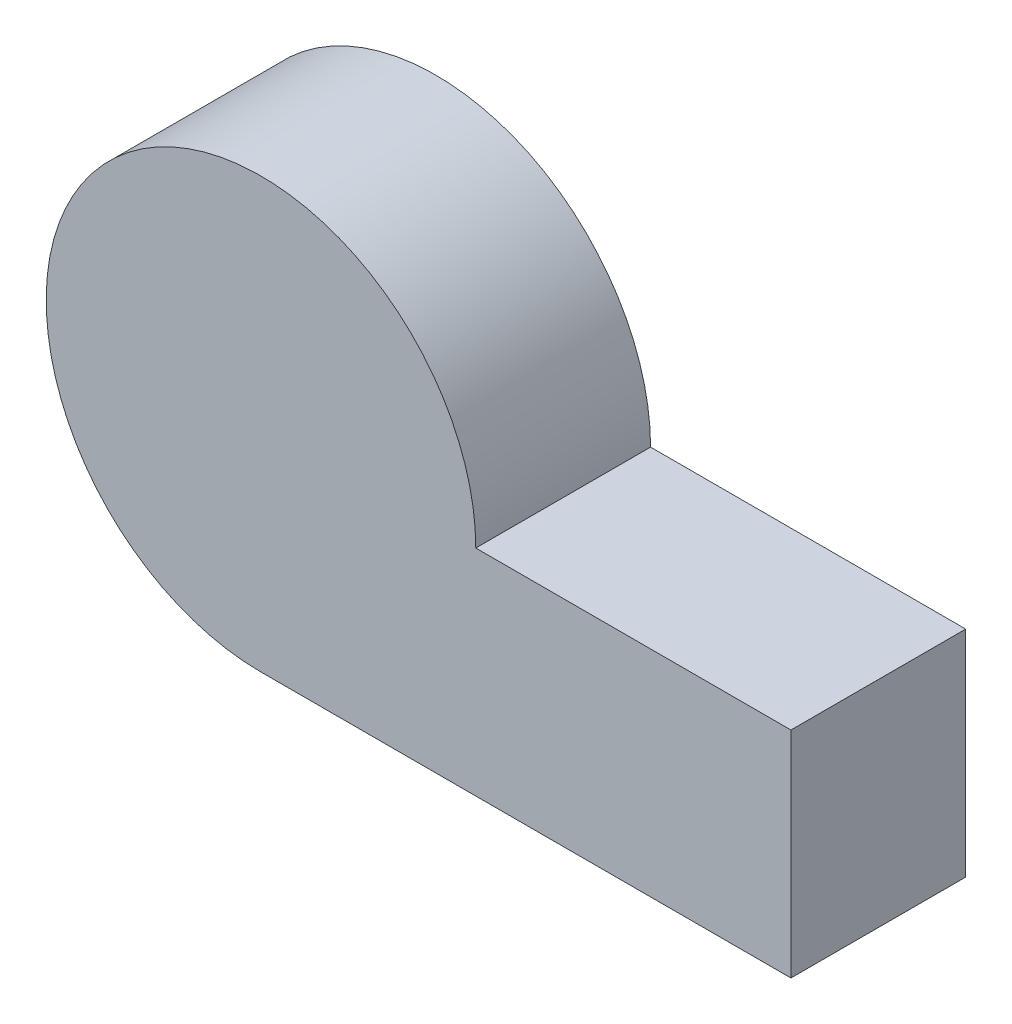
from build123d import *

# Parameters (mm, degrees)
EXTRUDE_2_DEPTH = 27


with BuildPart() as part:
    # ｽｹｯﾁ1 → ﾎﾞｽ - 押し出し2 (new body)
    with BuildSketch(Plane.XY):
        with BuildLine():
            Line((0, 0), (81.861577277, 0))
            Line((81.861577277, 0), (81.861577277, 33.179496516))
            Line((81.861577277, 33.179496516), (33.179496516, 33.179496516))
            ThreePointArc((33.179496516, 33.179496516), (-23.461446983, 56.640943498), (0, 0))
        make_face()
    extrude(amount=EXTRUDE_2_DEPTH)


solid = part.part
